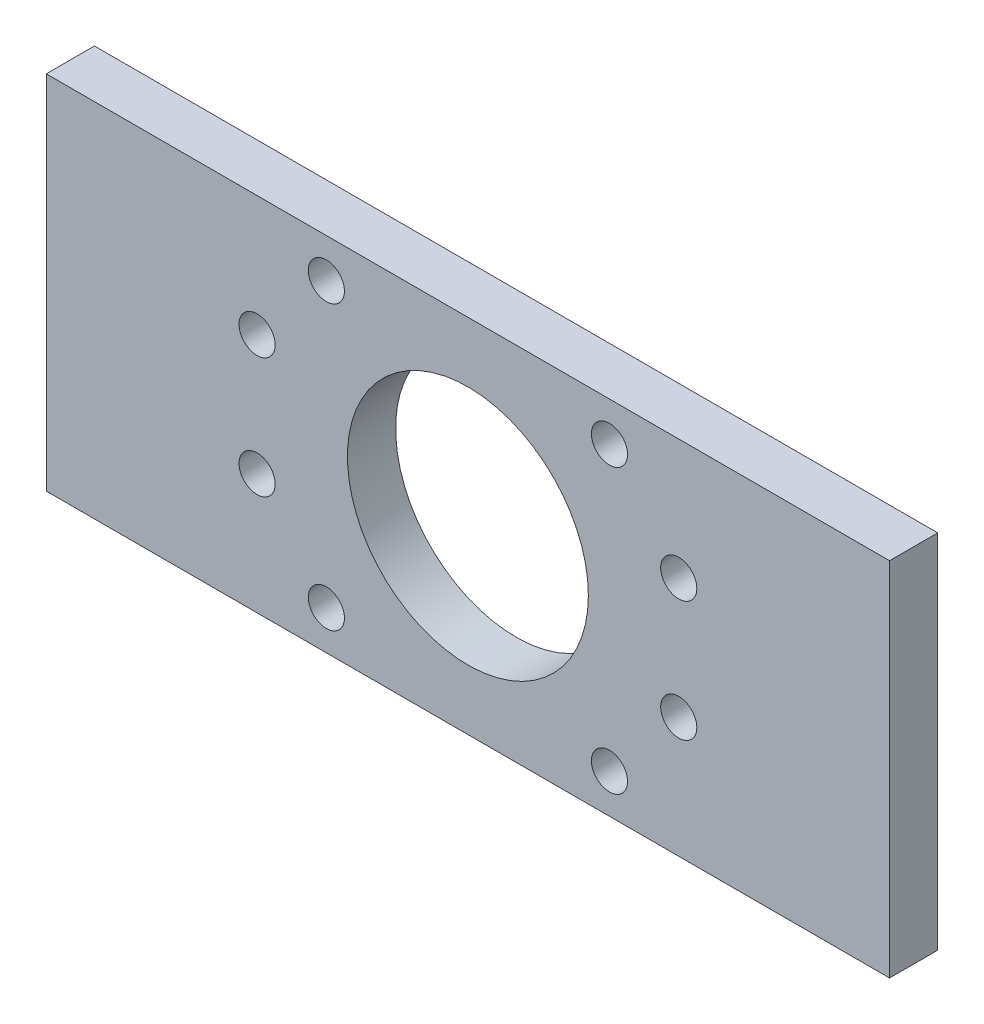
from build123d import *

# Parameters (mm, degrees)
ESQUISSE1_W             = 140
ESQUISSE1_H             = 60
BOSS_EXTRU_1_DEPTH      = 8
ESQUISSE2_R             = 20
ESQUISSE2_R_2           = 3
ENL_V_MAT_EXTRU_1_DEPTH = 9


with BuildPart() as part:
    # Esquisse1 → Boss.-Extru.1 (new body)
    with BuildSketch(Plane.XY):
        with Locations((-17.520553251, 12.112299465)):
            Rectangle(ESQUISSE1_W, ESQUISSE1_H)
    extrude(amount=BOSS_EXTRU_1_DEPTH)

    # Esquisse2 → Enlèv. mat.-Extru.1 (cut, through all)
    with BuildSketch(Plane.XY.offset(8)):
        with Locations((-17.520553251, 12.112299465)):
            Circle(ESQUISSE2_R)
        with Locations((-41.020553251, 35.612299465)):
            Circle(ESQUISSE2_R_2)
        with Locations((-41.020553251, -11.387700535)):
            Circle(ESQUISSE2_R_2)
        with Locations((5.979446749, 35.612299465)):
            Circle(ESQUISSE2_R_2)
        with Locations((5.979446749, -11.387700535)):
            Circle(ESQUISSE2_R_2)
        with Locations((-52.520553251, 22.112299465)):
            Circle(ESQUISSE2_R_2)
        with Locations((-52.520553251, 2.112299465)):
            Circle(ESQUISSE2_R_2)
        with Locations((17.479446749, 22.112299465)):
            Circle(ESQUISSE2_R_2)
        with Locations((17.479446749, 2.112299465)):
            Circle(ESQUISSE2_R_2)
    extrude(amount=-ENL_V_MAT_EXTRU_1_DEPTH, mode=Mode.SUBTRACT)


solid = part.part
